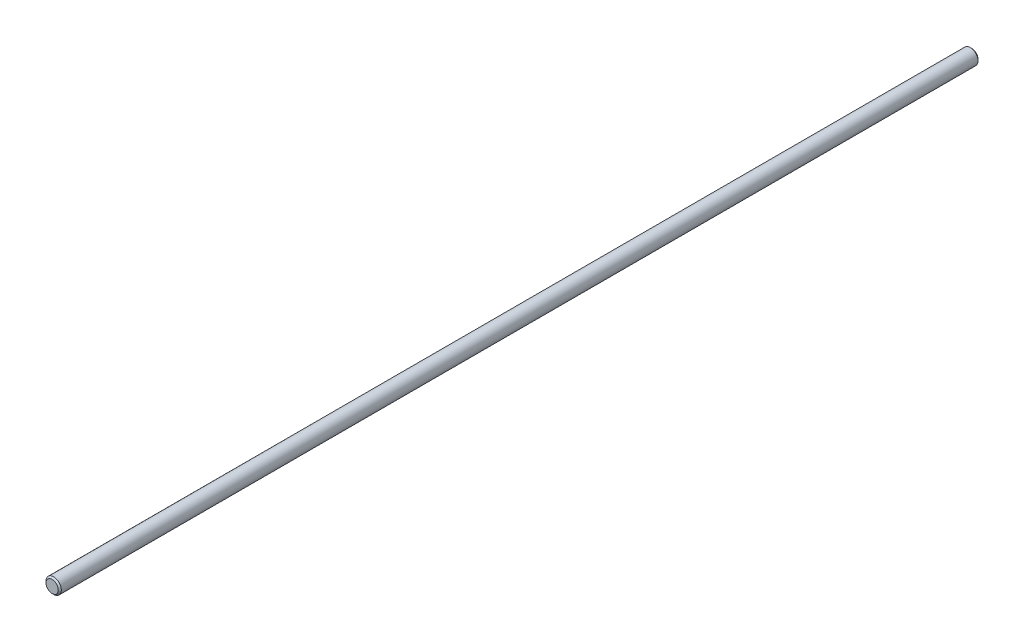
from build123d import *

# Parameters (mm, degrees)
SKETCH1_R      = 10
EXTRUDE1_DEPTH = 600
CHAMFER1_SIZE  = 2


with BuildPart() as part:
    # Sketch1 → Extrude1 (new body, symmetric)
    with BuildSketch(Plane.XY):
        Circle(SKETCH1_R)
    extrude(amount=EXTRUDE1_DEPTH, both=True)

    # Chamfer1
    chamfer1_edges = [part.edges().sort_by_distance(p)[0] for p in [
        (-10, 0, -600),
        (-10, 0, 600),
    ]]
    chamfer(chamfer1_edges, length=CHAMFER1_SIZE)


solid = part.part
